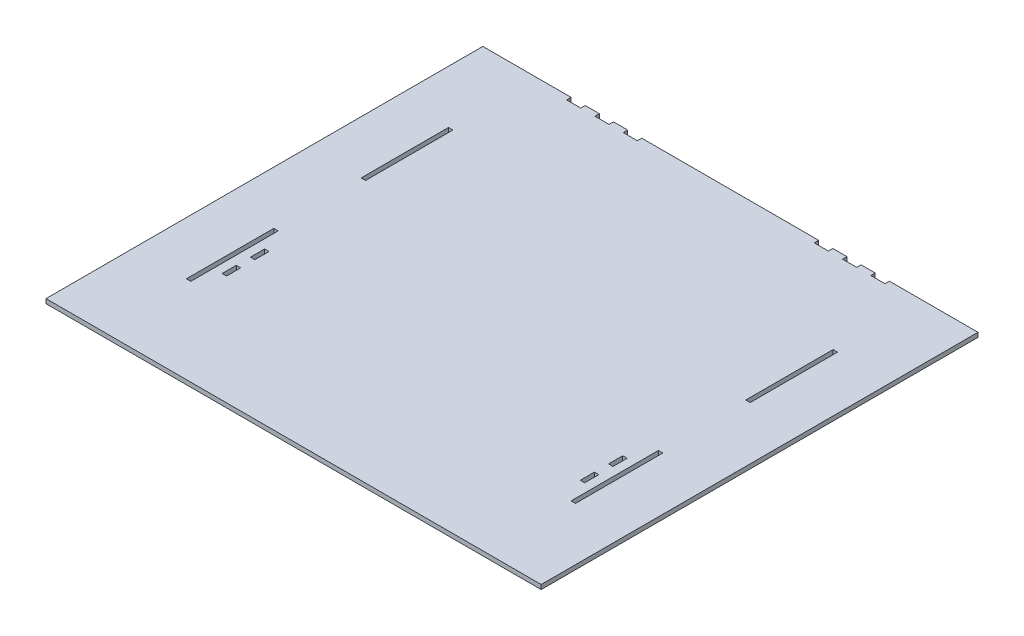
from build123d import *

# Parameters (mm, degrees)
SKETCH1_W           = 5
SKETCH1_H           = 98.8
SKETCH1_H_2         = 16.000962119
BOSS_EXTRUDE1_DEPTH = 5


with BuildPart() as part:
    # Sketch1 → Boss-Extrude1 (new body)
    with BuildSketch(Plane(origin=(0, 0, 0), x_dir=(1, 0, 0), z_dir=(0, 1, 0))):
        Polygon((-280, 247), (-180.213569057, 247), (-180.213569057, 242), (-164.213569057, 242), (-164.213569057, 247), (-148.213569057, 247), (-148.213569057, 242), (-132.213569057, 242), (-132.213569057, 247), (-116.213569057, 247), (-116.213569057, 242), (-100.213569057, 242), (-100.213569057, 247), (99.786430943, 247), (99.786430943, 242), (115.786430943, 242), (115.786430943, 247), (131.786430943, 247), (131.786430943, 242), (147.786430943, 242), (147.786430943, 247), (163.786430943, 247), (163.786430943, 242), (179.786430943, 242), (179.786430943, 247), (280, 247), (280, -247), (-280, -247), align=None)
        with Locations((-217.5, -98.8)):
            Rectangle(SKETCH1_W, SKETCH1_H, mode=Mode.SUBTRACT)
        with Locations((217.5, -98.8)):
            Rectangle(SKETCH1_W, SKETCH1_H, mode=Mode.SUBTRACT)
        with Locations((-202.5, -82.801443178)):
            Rectangle(SKETCH1_W, SKETCH1_H_2, mode=Mode.SUBTRACT)
        with Locations((217.5, 98.8)):
            Rectangle(SKETCH1_W, SKETCH1_H, mode=Mode.SUBTRACT)
        with Locations((-217.5, 98.8)):
            Rectangle(SKETCH1_W, SKETCH1_H, mode=Mode.SUBTRACT)
        with Locations((202.5, -114.803367415)):
            Rectangle(SKETCH1_W, SKETCH1_H_2, mode=Mode.SUBTRACT)
        with Locations((202.5, -82.801443178)):
            Rectangle(SKETCH1_W, SKETCH1_H_2, mode=Mode.SUBTRACT)
        with Locations((-202.5, -114.803367415)):
            Rectangle(SKETCH1_W, SKETCH1_H_2, mode=Mode.SUBTRACT)
    extrude(amount=BOSS_EXTRUDE1_DEPTH)


solid = part.part
